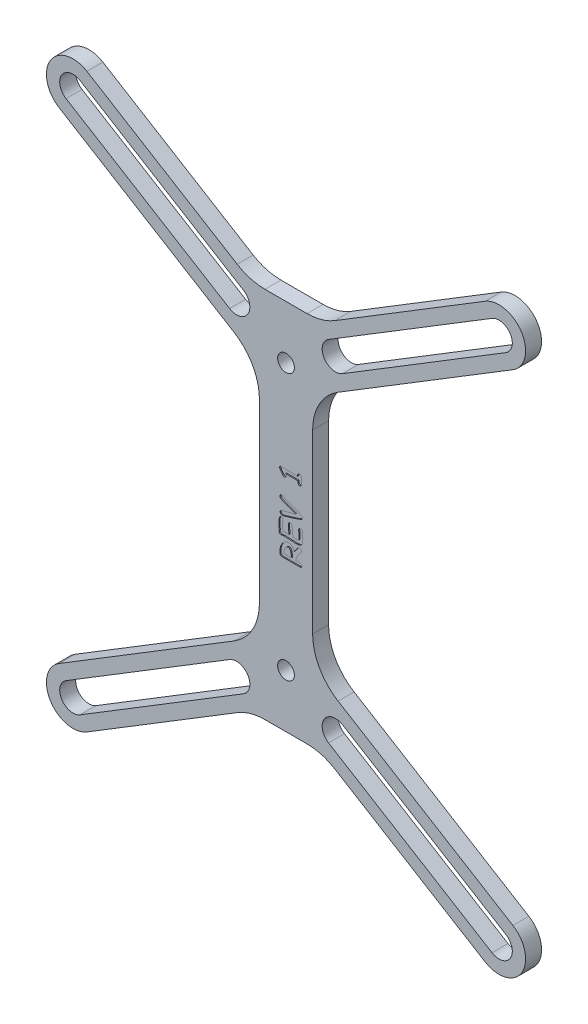
from build123d import *

# Parameters (mm, degrees)
SKETCH1_R           = 1.575
BOSS_EXTRUDE1_DEPTH = 3
CUT_EXTRUDE1_DEPTH  = 0.2


with BuildPart() as part:
    # Sketch1 → Boss-Extrude1 (new body)
    with BuildSketch(Plane.XY):
        with BuildLine():
            Line((-78.288917526, -9.797603918), (-50.063192097, -27.059285451))
            ThreePointArc((-50.063192097, -27.059285451), (-47.555969101, -28.153943521), (-44.845913527, -28.528165693))
            Line((-44.845913527, -28.528165693), (-36.940491232, -28.528165693))
            ThreePointArc((-36.940491232, -28.528165693), (-34.230435659, -28.153943521), (-31.723212662, -27.059285451))
            Line((-31.723212662, -27.059285451), (-3.497487233, -9.797603918))
            ThreePointArc((-3.497487233, -9.797603918), (3.37671193, -11.454524512), (1.719791336, -18.328723676))
            Line((1.719791336, -18.328723676), (-31.110480949, -38.406354852))
            ThreePointArc((-31.110480949, -38.406354852), (-34.615953829, -42.047320507), (-35.89320238, -46.93747461))
            Line((-35.89320238, -46.93747461), (-35.89320238, -80.118856775))
            ThreePointArc((-35.89320238, -80.118856775), (-34.615953829, -85.009010879), (-31.110480949, -88.649976534))
            Line((-31.110480949, -88.649976534), (1.719791336, -108.72760771))
            ThreePointArc((1.719791336, -108.72760771), (3.37671193, -115.601806874), (-3.497487233, -117.258727468))
            Line((-3.497487233, -117.258727468), (-31.723212662, -99.997045935))
            ThreePointArc((-31.723212662, -99.997045935), (-34.230435659, -98.902387865), (-36.940491232, -98.528165693))
            Line((-36.940491232, -98.528165693), (-44.845913527, -98.528165693))
            ThreePointArc((-44.845913527, -98.528165693), (-47.555969101, -98.902387865), (-50.063192097, -99.997045935))
            Line((-50.063192097, -99.997045935), (-78.288917526, -117.258727468))
            ThreePointArc((-78.288917526, -117.258727468), (-85.16311669, -115.601806874), (-83.506196095, -108.72760771))
            Line((-83.506196095, -108.72760771), (-50.67592381, -88.649976534))
            ThreePointArc((-50.67592381, -88.649976534), (-47.17045093, -85.009010879), (-45.89320238, -80.118856775))
            Line((-45.89320238, -80.118856775), (-45.89320238, -46.93747461))
            ThreePointArc((-45.89320238, -46.93747461), (-47.17045093, -42.047320507), (-50.67592381, -38.406354852))
            Line((-50.67592381, -38.406354852), (-83.506196095, -18.328723676))
            ThreePointArc((-83.506196095, -18.328723676), (-85.16311669, -11.454524512), (-78.288917526, -9.797603918))
        make_face()
        with Locations((-40.89320238, -88.528165693)):
            Circle(SKETCH1_R, mode=Mode.SUBTRACT)
        with Locations((-40.89320238, -38.528165693)):
            Circle(SKETCH1_R, mode=Mode.SUBTRACT)
        with BuildLine():
            Line((-82.201876453, -110.860387649), (-51.489845323, -92.078184799))
            ThreePointArc((-51.489845323, -92.078184799), (-48.052745742, -92.906645096), (-48.881206039, -96.343744678))
            Line((-48.881206039, -96.343744678), (-79.593237168, -115.125947528))
            ThreePointArc((-79.593237168, -115.125947528), (-83.03033675, -114.297487231), (-82.201876453, -110.860387649))
        make_face(mode=Mode.SUBTRACT)
        with BuildLine():
            Line((-30.296559436, -92.078184799), (0.415471694, -110.860387649))
            ThreePointArc((0.415471694, -110.860387649), (1.243931991, -114.297487231), (-2.193167591, -115.125947528))
            Line((-2.193167591, -115.125947528), (-32.90519872, -96.343744678))
            ThreePointArc((-32.90519872, -96.343744678), (-33.733659018, -92.906645096), (-30.296559436, -92.078184799))
        make_face(mode=Mode.SUBTRACT)
        with BuildLine():
            Line((-79.593237168, -11.930383857), (-48.881206039, -30.712586707))
            ThreePointArc((-48.881206039, -30.712586707), (-48.052745742, -34.149686289), (-51.489845323, -34.978146586))
            Line((-51.489845323, -34.978146586), (-82.201876453, -16.195943736))
            ThreePointArc((-82.201876453, -16.195943736), (-83.03033675, -12.758844154), (-79.593237168, -11.930383857))
        make_face(mode=Mode.SUBTRACT)
        with BuildLine():
            Line((0.415471694, -16.195943736), (-30.296559436, -34.978146586))
            ThreePointArc((-30.296559436, -34.978146586), (-33.733659018, -34.149686289), (-32.90519872, -30.712586707))
            Line((-32.90519872, -30.712586707), (-2.193167591, -11.930383857))
            ThreePointArc((-2.193167591, -11.930383857), (1.243931991, -12.758844154), (0.415471694, -16.195943736))
        make_face(mode=Mode.SUBTRACT)
    extrude(amount=BOSS_EXTRUDE1_DEPTH)

    # Sketch3 → Cut-Extrude1 (cut)
    with BuildSketch(Plane.XY.offset(3)):
        with BuildLine():
            add(Edge.make_bspline(
                [(-37.946643994, -67.703946943), (-37.94801712, -67.727536801), (-37.95073967, -67.774309314), (-37.972300047, -67.842742788), (-38.00796962, -67.907546345), (-38.040699509, -67.945888775), (-38.057581494, -67.965665693)],
                knots=[0, 0, 0, 0, 7.0663e-05, 0.000140107, 0.000213182, 0.000291025, 0.000291025, 0.000291025, 0.000291025], degree=3))
            add(Edge.make_bspline(
                [(-38.057581494, -67.965665693), (-38.118513774, -68.032704617), (-38.239038531, -68.165308384), (-38.404695199, -68.374150018), (-38.556288258, -68.587154817), (-38.693961893, -68.805219114), (-38.816172587, -69.028612594), (-38.925471999, -69.2564757), (-39.019782455, -69.489507045), (-39.071039403, -69.648662251), (-39.096643994, -69.728165693)],
                knots=[0, 0, 0, 0, 0.000271714, 0.000537454, 0.000799103, 0.00105574, 0.00131063, 0.001562578, 0.001813557, 0.002064069, 0.002064069, 0.002064069, 0.002064069], degree=3))
            add(Edge.make_bspline(
                [(-39.096643994, -69.728165693), (-39.03674816, -69.728165693), (-38.923987744, -69.728165693), (-38.765393994, -69.728165693), (-38.62815441, -69.728165693), (-38.512008577, -69.728165693), (-38.41721691, -69.728165693), (-38.343258577, -69.728165693), (-38.29065441, -69.728165693), (-38.26252941, -69.728165693), (-38.252112744, -69.728165693)],
                knots=[0, 0, 0, 0, 0.000179687, 0.000338281, 0.000475781, 0.000591406, 0.000686719, 0.000760156, 0.000813281, 0.000844531, 0.000844531, 0.000844531, 0.000844531], degree=3))
            add(Edge.make_bspline(
                [(-38.252112744, -69.728165693), (-38.228018483, -69.729273262), (-38.181130817, -69.731428604), (-38.113893955, -69.75106263), (-38.052563284, -69.782891975), (-37.998393202, -69.826613477), (-37.952764299, -69.879182157), (-37.920294463, -69.940102791), (-37.899713872, -70.007059626), (-37.897684969, -70.054054109), (-37.896643994, -70.078165693)],
                knots=[0, 0, 0, 0, 7.2146e-05, 0.000140397, 0.000208186, 0.00027822, 0.000348045, 0.000415509, 0.000483979, 0.000556125, 0.000556125, 0.000556125, 0.000556125], degree=3))
            add(Edge.make_bspline(
                [(-37.896643994, -70.078165693), (-37.897700605, -70.102269963), (-37.899759985, -70.149250191), (-37.920158621, -70.216429933), (-37.953627033, -70.277211505), (-37.999944638, -70.32947205), (-38.054228871, -70.373706451), (-38.116295574, -70.405238613), (-38.18426165, -70.424910627), (-38.231663247, -70.427060864), (-38.256018994, -70.428165693)],
                knots=[0, 0, 0, 0, 7.2146e-05, 0.000140616, 0.000208454, 0.000278789, 0.000348823, 0.000417306, 0.000486308, 0.000559233, 0.000559233, 0.000559233, 0.000559233], degree=3))
            add(Edge.make_bspline(
                [(-38.256018994, -70.428165693), (-38.29299816, -70.428165693), (-38.375289827, -70.428165693), (-38.511227327, -70.428165693), (-38.67190441, -70.428165693), (-38.848987744, -70.428165693), (-39.02581066, -70.428165693), (-39.186227327, -70.428165693), (-39.322164827, -70.428165693), (-39.40471691, -70.428165693), (-39.441956494, -70.428165693)],
                knots=[0, 0, 0, 0, 0.000110937, 0.000246875, 0.000407813, 0.000592969, 0.000778125, 0.000938281, 0.001074219, 0.001185937, 0.001185937, 0.001185937, 0.001185937], degree=3))
            Line((-39.441956494, -70.428165693), (-41.573987744, -70.428165693))
            add(Edge.make_bspline(
                [(-41.573987744, -70.428165693), (-41.601979025, -70.427059306), (-41.657620346, -70.42486002), (-41.73849047, -70.404276071), (-41.816039186, -70.372475538), (-41.862236056, -70.341021166), (-41.885706494, -70.325040693)],
                knots=[0, 0, 0, 0, 8.3827e-05, 0.000166632, 0.000248905, 0.000333871, 0.000333871, 0.000333871, 0.000333871], degree=3))
            add(Edge.make_bspline(
                [(-41.885706494, -70.325040693), (-41.900189952, -70.313770019), (-41.928533759, -70.291713562), (-41.963185459, -70.251611815), (-41.994098277, -70.210369522), (-42.016284314, -70.164185931), (-42.033902772, -70.115595291), (-42.044712726, -70.063280216), (-42.049515642, -70.007916377), (-42.047613317, -69.970094144), (-42.046643994, -69.950821943)],
                knots=[0, 0, 0, 0, 5.4916e-05, 0.000107469, 0.000158418, 0.000209079, 0.000260476, 0.000313185, 0.000368852, 0.000426686, 0.000426686, 0.000426686, 0.000426686], degree=3))
            add(Edge.make_bspline(
                [(-42.046643994, -69.950821943), (-42.04306086, -69.900556834), (-42.03633914, -69.806262856), (-42.026038224, -69.674782796), (-42.017465477, -69.562801844), (-42.010360978, -69.470620617), (-42.005041676, -69.397951), (-42.000741311, -69.344860312), (-41.999062241, -69.311184835), (-41.997196099, -69.295350376), (-41.996643994, -69.290665693)],
                knots=[0, 0, 0, 0, 0.000151177, 0.000283599, 0.000395648, 0.000488103, 0.000560965, 0.000614233, 0.000647908, 0.000662057, 0.000662057, 0.000662057, 0.000662057], degree=3))
            add(Edge.make_bspline(
                [(-41.996643994, -69.290665693), (-41.988273617, -69.230844456), (-41.972108507, -69.115315979), (-41.932255207, -68.950338653), (-41.883702436, -68.798492424), (-41.839811946, -68.705372819), (-41.818518994, -68.660196943)],
                knots=[0, 0, 0, 0, 0.000181103, 0.000349752, 0.000508607, 0.000658292, 0.000658292, 0.000658292, 0.000658292], degree=3))
            add(Edge.make_bspline(
                [(-41.818518994, -68.660196943), (-41.794961831, -68.614408759), (-41.748659411, -68.524410498), (-41.673994786, -68.39618382), (-41.596726829, -68.276980891), (-41.51936644, -68.16542509), (-41.4376406, -68.064104928), (-41.35488791, -67.970611015), (-41.269901128, -67.885903429), (-41.182031493, -67.810960226), (-41.093027121, -67.743861578), (-41.001103136, -67.68667641), (-40.907278255, -67.6381627), (-40.811252898, -67.597827282), (-40.712980642, -67.566485725), (-40.612487989, -67.544834027), (-40.510053033, -67.530917507), (-40.440959881, -67.529089918), (-40.406018994, -67.528165693)],
                knots=[0, 0, 0, 0, 0.00015446, 0.000303597, 0.000444889, 0.000580575, 0.000710638, 0.000835142, 0.00095502, 0.001070264, 0.001181358, 0.001289097, 0.001394621, 0.001497926, 0.001601205, 0.00170357, 0.001805997, 0.001910789, 0.001910789, 0.001910789, 0.001910789], degree=3))
            add(Edge.make_bspline(
                [(-40.406018994, -67.528165693), (-40.377335709, -67.528941421), (-40.320800891, -67.530470384), (-40.237423726, -67.541860235), (-40.156488148, -67.559578278), (-40.077988251, -67.585572136), (-40.002201476, -67.619243738), (-39.929157083, -67.660299744), (-39.858348954, -67.708085705), (-39.790568361, -67.763989432), (-39.724494721, -67.826431372), (-39.662291679, -67.897342845), (-39.601955567, -67.974597541), (-39.544855438, -68.059618408), (-39.490138913, -68.15198371), (-39.438169105, -68.252061425), (-39.387799267, -68.358955559), (-39.357971741, -68.43372714), (-39.342737744, -68.471915693)],
                knots=[0, 0, 0, 0, 8.6026e-05, 0.000169558, 0.000252008, 0.000334277, 0.000417171, 0.000500414, 0.000585354, 0.000673084, 0.000763709, 0.000857784, 0.000955768, 0.00105761, 0.001164798, 0.001277669, 0.001395803, 0.001519122, 0.001519122, 0.001519122, 0.001519122], degree=3))
            add(Edge.make_bspline(
                [(-39.342737744, -68.471915693), (-39.310298359, -68.415184995), (-39.24708115, -68.30462937), (-39.148196207, -68.146271602), (-39.048921734, -67.998721382), (-38.950303435, -67.860959497), (-38.850139699, -67.73478142), (-38.749002672, -67.620035159), (-38.648863696, -67.514397443), (-38.578568182, -67.451173738), (-38.544300244, -67.420353193)],
                knots=[0, 0, 0, 0, 0.000196038, 0.000382034, 0.00055993, 0.00072949, 0.000890179, 0.001042972, 0.001188287, 0.001326504, 0.001326504, 0.001326504, 0.001326504], degree=3))
            add(Edge.make_bspline(
                [(-38.544300244, -67.420353193), (-38.52682381, -67.406069168), (-38.492612419, -67.37810715), (-38.433863174, -67.34948095), (-38.372505499, -67.330996672), (-38.330370731, -67.329114099), (-38.309143994, -67.328165693)],
                knots=[0, 0, 0, 0, 6.75e-05, 0.000132137, 0.0001947, 0.000258217, 0.000258217, 0.000258217, 0.000258217], degree=3))
            add(Edge.make_bspline(
                [(-38.309143994, -67.328165693), (-38.285009966, -67.329428518), (-38.237591458, -67.331909716), (-38.169830124, -67.354305414), (-38.107059808, -67.389398259), (-38.052396515, -67.438547142), (-38.005316968, -67.495541419), (-37.970847449, -67.559935789), (-37.950843206, -67.63037859), (-37.94806328, -67.679081668), (-37.946643994, -67.703946943)],
                knots=[0, 0, 0, 0, 7.2218e-05, 0.000141894, 0.000211858, 0.000286602, 0.00036103, 0.000432675, 0.000504146, 0.000578697, 0.000578697, 0.000578697, 0.000578697], degree=3))
        make_face()
        with BuildLine():
            add(Edge.make_bspline(
                [(-41.275550244, -69.415665693), (-41.275804849, -69.418791139), (-41.276547596, -69.42790886), (-41.278302709, -69.445844221), (-41.279455784, -69.472193578), (-41.282026816, -69.507074291), (-41.285245279, -69.550280033), (-41.28812092, -69.602136058), (-41.292130522, -69.662286124), (-41.295073988, -69.70524956), (-41.296643994, -69.728165693)],
                knots=[0, 0, 0, 0, 9.407e-06, 2.7444e-05, 5.4052e-05, 8.8507e-05, 0.000132369, 0.000184026, 0.000244309, 0.000313218, 0.000313218, 0.000313218, 0.000313218], degree=3))
            Line((-41.296643994, -69.728165693), (-39.896643994, -69.728165693))
            add(Edge.make_bspline(
                [(-39.896643994, -69.728165693), (-39.896063647, -69.707333528), (-39.894975605, -69.668277055), (-39.894515115, -69.629208254), (-39.894300244, -69.610978193)],
                knots=[0, 0, 0, 0, 6.252e-05, 0.000117213, 0.000117213, 0.000117213, 0.000117213], degree=3))
            add(Edge.make_bspline(
                [(-39.894300244, -69.610978193), (-39.894643523, -69.558102426), (-39.89530682, -69.455934021), (-39.903370274, -69.308179304), (-39.915687067, -69.171083027), (-39.932438429, -69.044259041), (-39.95491402, -68.928163586), (-39.982105697, -68.822601569), (-40.014393423, -68.727547016), (-40.041464736, -68.669367701), (-40.054456494, -68.641446943)],
                knots=[0, 0, 0, 0, 0.000158611, 0.000306474, 0.000443763, 0.000571487, 0.000690078, 0.000798277, 0.000898341, 0.000990674, 0.000990674, 0.000990674, 0.000990674], degree=3))
            add(Edge.make_bspline(
                [(-40.054456494, -68.641446943), (-40.06666721, -68.61914395), (-40.091159557, -68.574408439), (-40.133384043, -68.509959676), (-40.182057134, -68.449034772), (-40.234559402, -68.393208766), (-40.285379775, -68.344648248), (-40.331179051, -68.307964677), (-40.371155024, -68.284056605), (-40.397234228, -68.279927615), (-40.408362744, -68.278165693)],
                knots=[0, 0, 0, 0, 7.6263e-05, 0.000152969, 0.000230812, 0.000309857, 0.000382811, 0.000441259, 0.000486342, 0.000519899, 0.000519899, 0.000519899, 0.000519899], degree=3))
            add(Edge.make_bspline(
                [(-40.408362744, -68.278165693), (-40.432934813, -68.279504973), (-40.482398518, -68.282200953), (-40.556302567, -68.300153316), (-40.629119914, -68.330119919), (-40.700849161, -68.372640378), (-40.772394938, -68.426010091), (-40.842120194, -68.492376657), (-40.912500765, -68.569179032), (-40.955493152, -68.626963701), (-40.977893994, -68.657071943)],
                knots=[0, 0, 0, 0, 7.3703e-05, 0.000148364, 0.000226852, 0.000309125, 0.000397875, 0.000494054, 0.000597478, 0.000709989, 0.000709989, 0.000709989, 0.000709989], degree=3))
            add(Edge.make_bspline(
                [(-40.977893994, -68.657071943), (-40.998549007, -68.687055273), (-41.039477072, -68.74646747), (-41.094121779, -68.838391065), (-41.141181343, -68.932043987), (-41.181644843, -69.026560274), (-41.216652114, -69.121733391), (-41.242785813, -69.218600458), (-41.263854527, -69.316313418), (-41.271647027, -69.382508816), (-41.275550244, -69.415665693)],
                knots=[0, 0, 0, 0, 0.000109207, 0.000216395, 0.000320513, 0.000423404, 0.000524726, 0.000624423, 0.00072417, 0.000824273, 0.000824273, 0.000824273, 0.000824273], degree=3))
        make_face(mode=Mode.SUBTRACT)
        with BuildLine():
            add(Edge.make_bspline(
                [(-41.446643994, -64.339884443), (-41.447277487, -64.357896108), (-41.448578566, -64.394888768), (-41.455044871, -64.431338352), (-41.458362744, -64.450040693)],
                knots=[0, 0, 0, 0, 5.3997e-05, 0.000110899, 0.000110899, 0.000110899, 0.000110899], degree=3))
            add(Edge.make_bspline(
                [(-41.458362744, -64.450040693), (-41.471768459, -64.520243843), (-41.498287495, -64.659118922), (-41.526438087, -64.867399853), (-41.543339495, -65.072672326), (-41.545550603, -65.208603896), (-41.546643994, -65.275821943)],
                knots=[0, 0, 0, 0, 0.000214383, 0.00042409, 0.000630213, 0.000831849, 0.000831849, 0.000831849, 0.000831849], degree=3))
            add(Edge.make_bspline(
                [(-41.546643994, -65.275821943), (-41.545348261, -65.343829472), (-41.542658029, -65.485028417), (-41.522665253, -65.703498576), (-41.491510464, -65.936554894), (-41.461951804, -66.095731476), (-41.446643994, -66.178165693)],
                knots=[0, 0, 0, 0, 0.000204002, 0.000423554, 0.00065768, 0.000909171, 0.000909171, 0.000909171, 0.000909171], degree=3))
            add(Edge.make_bspline(
                [(-41.446643994, -66.178165693), (-41.413831494, -66.178165693), (-41.34456066, -66.178165693), (-41.23518566, -66.178165693), (-41.114612744, -66.178165693), (-40.98284191, -66.178165693), (-40.839612744, -66.178165693), (-40.68518566, -66.178165693), (-40.51956066, -66.178165693), (-40.40549816, -66.178165693), (-40.346643994, -66.178165693)],
                knots=[0, 0, 0, 0, 9.8437e-05, 0.000207813, 0.000328125, 0.000460156, 0.000603125, 0.000757813, 0.000923437, 0.0011, 0.0011, 0.0011, 0.0011], degree=3))
            add(Edge.make_bspline(
                [(-40.346643994, -66.178165693), (-40.347358768, -66.162016044), (-40.349135186, -66.121879555), (-40.354506826, -66.050335643), (-40.359170949, -65.955723168), (-40.367860185, -65.838362667), (-40.375678834, -65.697655379), (-40.38710988, -65.53390121), (-40.39944828, -65.347172201), (-40.408346576, -65.215143822), (-40.413050244, -65.145353193)],
                knots=[0, 0, 0, 0, 4.8494e-05, 0.000120522, 0.000215211, 0.000332659, 0.000473546, 0.000637973, 0.00082511, 0.001034956, 0.001034956, 0.001034956, 0.001034956], degree=3))
            add(Edge.make_bspline(
                [(-40.413050244, -65.145353193), (-40.415630764, -65.105247588), (-40.420540428, -65.028943204), (-40.427909819, -64.920125372), (-40.433154649, -64.822699251), (-40.437755687, -64.73701893), (-40.44206484, -64.663090129), (-40.4441862, -64.600566342), (-40.445874027, -64.549526722), (-40.4464121, -64.519312252), (-40.446643994, -64.506290693)],
                knots=[0, 0, 0, 0, 0.000120566, 0.000229387, 0.000327196, 0.000413262, 0.000486803, 0.000549347, 0.000600933, 0.000640003, 0.000640003, 0.000640003, 0.000640003], degree=3))
            add(Edge.make_bspline(
                [(-40.446643994, -64.506290693), (-40.445419133, -64.481186429), (-40.443013155, -64.431874455), (-40.424834016, -64.361023994), (-40.394218322, -64.295954418), (-40.352553764, -64.237749816), (-40.300186943, -64.188965489), (-40.238862572, -64.152664397), (-40.168758672, -64.132043735), (-40.119694481, -64.129488309), (-40.094300244, -64.128165693)],
                knots=[0, 0, 0, 0, 7.526e-05, 0.000147832, 0.000217731, 0.000289932, 0.000361249, 0.000430925, 0.000501864, 0.000577971, 0.000577971, 0.000577971, 0.000577971], degree=3))
            add(Edge.make_bspline(
                [(-40.094300244, -64.128165693), (-40.069985476, -64.129154143), (-40.023665659, -64.131037149), (-39.958439623, -64.146838496), (-39.901181354, -64.172824743), (-39.852462524, -64.21063239), (-39.811978648, -64.259002659), (-39.781755908, -64.318530836), (-39.75875997, -64.387530724), (-39.750832997, -64.437628862), (-39.746643994, -64.464103193)],
                knots=[0, 0, 0, 0, 7.2862e-05, 0.000138802, 0.00019997, 0.000260131, 0.000322249, 0.000387599, 0.000459244, 0.000539535, 0.000539535, 0.000539535, 0.000539535], degree=3))
            add(Edge.make_bspline(
                [(-39.746643994, -64.464103193), (-39.745434569, -64.482860517), (-39.742879446, -64.52248868), (-39.736861174, -64.585163209), (-39.731513405, -64.654446344), (-39.726530362, -64.730305751), (-39.718825712, -64.812502076), (-39.712246149, -64.901361876), (-39.704306373, -64.996664583), (-39.698736431, -65.062281076), (-39.695862744, -65.096134443)],
                knots=[0, 0, 0, 0, 5.6385e-05, 0.000119124, 0.00018887, 0.000264849, 0.000347181, 0.00043652, 0.000532152, 0.000634078, 0.000634078, 0.000634078, 0.000634078], degree=3))
            add(Edge.make_bspline(
                [(-39.695862744, -65.096134443), (-39.692452325, -65.129465262), (-39.685233205, -65.200019399), (-39.67433901, -65.311743236), (-39.662631191, -65.4354423), (-39.649998011, -65.570825189), (-39.637704493, -65.718263008), (-39.624408325, -65.877636321), (-39.61020746, -66.048959508), (-39.60125658, -66.167222278), (-39.596643994, -66.228165693)],
                knots=[0, 0, 0, 0, 0.000100514, 0.000212767, 0.00033676, 0.000473271, 0.000620677, 0.000780604, 0.000953054, 0.001136406, 0.001136406, 0.001136406, 0.001136406], degree=3))
            add(Edge.make_bspline(
                [(-39.596643994, -66.228165693), (-39.545602327, -66.228165693), (-39.448727327, -66.228165693), (-39.311227327, -66.228165693), (-39.189352327, -66.228165693), (-39.11331066, -66.228165693), (-39.077893994, -66.228165693)],
                knots=[0, 0, 0, 0, 0.000153125, 0.000290625, 0.0004125, 0.00051875, 0.00051875, 0.00051875, 0.00051875], degree=3))
            add(Edge.make_bspline(
                [(-39.077893994, -66.228165693), (-39.038829788, -66.228036152), (-38.965120613, -66.227791725), (-38.861200099, -66.225475728), (-38.770788259, -66.221812841), (-38.693694104, -66.216369514), (-38.629939228, -66.209955983), (-38.579486038, -66.201121551), (-38.541383074, -66.192871111), (-38.522299535, -66.182388184), (-38.514612744, -66.178165693)],
                knots=[0, 0, 0, 0, 0.00011719, 0.000221123, 0.000311832, 0.000388589, 0.000453037, 0.00050377, 0.000542621, 0.000568825, 0.000568825, 0.000568825, 0.000568825], degree=3))
            add(Edge.make_bspline(
                [(-38.514612744, -66.178165693), (-38.511811666, -66.174363836), (-38.504735637, -66.164759655), (-38.498624267, -66.14331258), (-38.493682834, -66.114007242), (-38.489024571, -66.075897483), (-38.485121891, -66.029277603), (-38.483182118, -65.973749196), (-38.481547919, -65.909685841), (-38.481202525, -65.864104795), (-38.481018994, -65.839884443)],
                knots=[0, 0, 0, 0, 1.4084e-05, 3.5579e-05, 6.5766e-05, 0.000103558, 0.000150596, 0.000206114, 0.000270195, 0.000342856, 0.000342856, 0.000342856, 0.000342856], degree=3))
            add(Edge.make_bspline(
                [(-38.481018994, -65.839884443), (-38.481322747, -65.80863501), (-38.482001125, -65.738845069), (-38.482050482, -65.62371905), (-38.486214995, -65.487550084), (-38.488711645, -65.337278191), (-38.491922888, -65.187024042), (-38.494248705, -65.050564916), (-38.495910082, -64.935460656), (-38.496417015, -64.865666038), (-38.496643994, -64.834415693)],
                knots=[0, 0, 0, 0, 9.3753e-05, 0.000209381, 0.000345354, 0.000502417, 0.00066026, 0.000796218, 0.000911853, 0.001005607, 0.001005607, 0.001005607, 0.001005607], degree=3))
            add(Edge.make_bspline(
                [(-38.496643994, -64.834415693), (-38.496789943, -64.824514692), (-38.497116999, -64.802327702), (-38.500479829, -64.766085657), (-38.506314988, -64.723447244), (-38.512937335, -64.676589891), (-38.520239503, -64.629583396), (-38.52443865, -64.5870453), (-38.528275926, -64.551409652), (-38.528551254, -64.529996361), (-38.528675244, -64.520353193)],
                knots=[0, 0, 0, 0, 2.9698e-05, 6.6549e-05, 0.00010909, 0.000158808, 0.000208527, 0.00025175, 0.000287045, 0.000315962, 0.000315962, 0.000315962, 0.000315962], degree=3))
            add(Edge.make_bspline(
                [(-38.528675244, -64.520353193), (-38.527785396, -64.495227612), (-38.526048005, -64.446170954), (-38.507813878, -64.376191778), (-38.481003514, -64.310865485), (-38.453464995, -64.273515664), (-38.439612744, -64.254728193)],
                knots=[0, 0, 0, 0, 7.5199e-05, 0.000146823, 0.000215759, 0.000285532, 0.000285532, 0.000285532, 0.000285532], degree=3))
            add(Edge.make_bspline(
                [(-38.439612744, -64.254728193), (-38.422264593, -64.235242603), (-38.387966383, -64.19671856), (-38.320349562, -64.156046756), (-38.242765378, -64.132203952), (-38.187707091, -64.129545067), (-38.159143994, -64.128165693)],
                knots=[0, 0, 0, 0, 7.7894e-05, 0.000154001, 0.000233324, 0.000318838, 0.000318838, 0.000318838, 0.000318838], degree=3))
            add(Edge.make_bspline(
                [(-38.159143994, -64.128165693), (-38.135095487, -64.12889386), (-38.089091216, -64.130286827), (-38.024069442, -64.145529817), (-37.966332465, -64.169857998), (-37.916298927, -64.204520623), (-37.874859863, -64.250112454), (-37.840194176, -64.30427868), (-37.814400764, -64.369105644), (-37.803787742, -64.416002995), (-37.798206494, -64.440665693)],
                knots=[0, 0, 0, 0, 7.2028e-05, 0.000137787, 0.00019903, 0.000259064, 0.000318767, 0.000382701, 0.000451032, 0.000526826, 0.000526826, 0.000526826, 0.000526826], degree=3))
            add(Edge.make_bspline(
                [(-37.798206494, -64.440665693), (-37.794128823, -64.465900775), (-37.785032055, -64.522197064), (-37.77418292, -64.616251288), (-37.766494793, -64.728378707), (-37.758124725, -64.858284989), (-37.753267842, -65.006006447), (-37.749329574, -65.171636573), (-37.747048934, -65.355242964), (-37.746783104, -65.483633915), (-37.746643994, -65.550821943)],
                knots=[0, 0, 0, 0, 7.6682e-05, 0.000171068, 0.000283896, 0.000413818, 0.000561576, 0.000727247, 0.000910855, 0.001112419, 0.001112419, 0.001112419, 0.001112419], degree=3))
            add(Edge.make_bspline(
                [(-37.746643994, -65.550821943), (-37.747367701, -65.620370764), (-37.748748334, -65.753050673), (-37.759755063, -65.942546525), (-37.776850311, -66.113251492), (-37.80255544, -66.265104423), (-37.834213838, -66.398602231), (-37.874992936, -66.51263274), (-37.921165225, -66.609377724), (-37.961913509, -66.662058989), (-37.981018994, -66.686759443)],
                knots=[0, 0, 0, 0, 0.00020863, 0.000398009, 0.000569267, 0.000723006, 0.000859812, 0.000980158, 0.001086022, 0.001179475, 0.001179475, 0.001179475, 0.001179475], degree=3))
            add(Edge.make_bspline(
                [(-37.981018994, -66.686759443), (-38.004989368, -66.710355123), (-38.055233923, -66.759814278), (-38.150653105, -66.81840324), (-38.263378456, -66.867883721), (-38.394569488, -66.909370457), (-38.544598935, -66.940368871), (-38.713266925, -66.962632418), (-38.900348366, -66.975564246), (-39.031258502, -66.977271972), (-39.099768994, -66.978165693)],
                knots=[0, 0, 0, 0, 0.000100639, 0.00021095, 0.000333347, 0.000469484, 0.000622866, 0.000792356, 0.000979547, 0.001185069, 0.001185069, 0.001185069, 0.001185069], degree=3))
            add(Edge.make_bspline(
                [(-39.099768994, -66.978165693), (-39.131280588, -66.977996147), (-39.198217579, -66.977635997), (-39.304213641, -66.975117221), (-39.421405587, -66.971193577), (-39.549792407, -66.96564269), (-39.689378643, -66.958602901), (-39.840160305, -66.949964994), (-40.002140449, -66.939785412), (-40.171644056, -66.92816675), (-40.341147295, -66.916541888), (-40.502868962, -66.906395549), (-40.653127975, -66.89772983), (-40.792192464, -66.890668071), (-40.920319972, -66.885138359), (-41.037251741, -66.881228123), (-41.14272654, -66.878694667), (-41.209142795, -66.878334952), (-41.240393994, -66.878165693)],
                knots=[0, 0, 0, 0, 9.4534e-05, 0.00020081, 0.000318063, 0.000446305, 0.000586325, 0.000737351, 0.000899388, 0.001073221, 0.001247054, 0.001409092, 0.001559338, 0.001698578, 0.001826819, 0.001944072, 0.002049567, 0.00214332, 0.00214332, 0.00214332, 0.00214332], degree=3))
            add(Edge.make_bspline(
                [(-41.240393994, -66.878165693), (-41.257849467, -66.878525626), (-41.296456222, -66.879321701), (-41.360014828, -66.884534589), (-41.434778173, -66.892290417), (-41.516704107, -66.903104571), (-41.598352099, -66.914039966), (-41.67259223, -66.921835765), (-41.735894577, -66.927006379), (-41.774501117, -66.92780473), (-41.791956494, -66.928165693)],
                knots=[0, 0, 0, 0, 5.2367e-05, 0.000115822, 0.000191227, 0.000277858, 0.000363714, 0.000438343, 0.000501797, 0.000554164, 0.000554164, 0.000554164, 0.000554164], degree=3))
            add(Edge.make_bspline(
                [(-41.791956494, -66.928165693), (-41.823551279, -66.927295069), (-41.883366798, -66.925646797), (-41.96701943, -66.908765258), (-42.038282434, -66.880087842), (-42.096511964, -66.839074154), (-42.142584377, -66.786899688), (-42.174999964, -66.722443997), (-42.193532622, -66.646633819), (-42.195569822, -66.592596116), (-42.196643994, -66.564103193)],
                knots=[0, 0, 0, 0, 9.4689e-05, 0.000179267, 0.000254567, 0.000323499, 0.00039104, 0.00046127, 0.00053782, 0.000623206, 0.000623206, 0.000623206, 0.000623206], degree=3))
            add(Edge.make_bspline(
                [(-42.196643994, -66.564103193), (-42.195973599, -66.545278643), (-42.194645281, -66.507979732), (-42.181504769, -66.453397536), (-42.160405873, -66.401196001), (-42.140374835, -66.369304832), (-42.130237744, -66.353165693)],
                knots=[0, 0, 0, 0, 5.6385e-05, 0.000111722, 0.000167432, 0.000224512, 0.000224512, 0.000224512, 0.000224512], degree=3))
            add(Edge.make_bspline(
                [(-42.130237744, -66.353165693), (-42.14146284, -66.303488234), (-42.163551482, -66.205733384), (-42.191207567, -66.060463944), (-42.211534832, -65.918881553), (-42.229541057, -65.73760341), (-42.24301867, -65.520299091), (-42.245460978, -65.34875766), (-42.246643994, -65.265665693)],
                knots=[0, 0, 0, 0, 0.000152784, 0.000300647, 0.000443504, 0.000581722, 0.000847073, 0.001096352, 0.001096352, 0.001096352, 0.001096352], degree=3))
            add(Edge.make_bspline(
                [(-42.246643994, -65.265665693), (-42.246218855, -65.212272154), (-42.245390999, -65.108301166), (-42.238268384, -64.95664684), (-42.226710529, -64.813308622), (-42.210402768, -64.67802657), (-42.189565521, -64.550754482), (-42.163826046, -64.431840824), (-42.133803816, -64.32105438), (-42.108802934, -64.25120081), (-42.096643994, -64.217228193)],
                knots=[0, 0, 0, 0, 0.000160173, 0.000311899, 0.000455347, 0.000591495, 0.000720574, 0.000842091, 0.000956383, 0.001064597, 0.001064597, 0.001064597, 0.001064597], degree=3))
            add(Edge.make_bspline(
                [(-42.096643994, -64.217228193), (-42.089331819, -64.198257077), (-42.07529865, -64.161848636), (-42.047002347, -64.112716832), (-42.013446878, -64.071731135), (-41.977197413, -64.036647239), (-41.935073711, -64.01021683), (-41.888813652, -63.991499563), (-41.838038948, -63.980449916), (-41.802948304, -63.978940798), (-41.784925244, -63.978165693)],
                knots=[0, 0, 0, 0, 6.0937e-05, 0.000116948, 0.000169169, 0.000219468, 0.000267583, 0.000317344, 0.000368526, 0.000422574, 0.000422574, 0.000422574, 0.000422574], degree=3))
            add(Edge.make_bspline(
                [(-41.784925244, -63.978165693), (-41.76423682, -63.979473747), (-41.723184076, -63.982069364), (-41.663433212, -63.999764739), (-41.607579878, -64.029964347), (-41.575564681, -64.058209779), (-41.559143994, -64.072696943)],
                knots=[0, 0, 0, 0, 6.2034e-05, 0.000123097, 0.000185323, 0.000250846, 0.000250846, 0.000250846, 0.000250846], degree=3))
            add(Edge.make_bspline(
                [(-41.559143994, -64.072696943), (-41.541876895, -64.090777448), (-41.508043609, -64.126204531), (-41.472014322, -64.191186026), (-41.450439994, -64.263253649), (-41.447928657, -64.313950633), (-41.446643994, -64.339884443)],
                knots=[0, 0, 0, 0, 7.4743e-05, 0.000146452, 0.000220609, 0.000298272, 0.000298272, 0.000298272, 0.000298272], degree=3))
        make_face()
        with BuildLine():
            add(Edge.make_bspline(
                [(-39.100550244, -62.203165693), (-39.182047295, -62.171100392), (-39.340812435, -62.10863369), (-39.572839243, -62.017995379), (-39.792167024, -61.932984319), (-39.998634255, -61.85318568), (-40.191967941, -61.778811113), (-40.373017531, -61.711169017), (-40.540594914, -61.647357572), (-40.648682454, -61.607993004), (-40.700550244, -61.589103193)],
                knots=[0, 0, 0, 0, 0.000262735, 0.000511836, 0.000747305, 0.000968414, 0.001175893, 0.001368736, 0.00154823, 0.001713829, 0.001713829, 0.001713829, 0.001713829], degree=3))
            add(Edge.make_bspline(
                [(-40.700550244, -61.589103193), (-40.805709522, -61.550686035), (-41.016092069, -61.473828343), (-41.227063629, -61.398602536), (-41.332581494, -61.360978193)],
                knots=[0, 0, 0, 0, 0.000335869, 0.000671943, 0.000671943, 0.000671943, 0.000671943], degree=3))
            add(Edge.make_bspline(
                [(-41.332581494, -61.360978193), (-41.392103865, -61.335533711), (-41.505529975, -61.287046588), (-41.661068905, -61.204513223), (-41.796715643, -61.121331202), (-41.874567568, -61.058135406), (-41.911487744, -61.028165693)],
                knots=[0, 0, 0, 0, 0.000194106, 0.000369889, 0.000527896, 0.000670418, 0.000670418, 0.000670418, 0.000670418], degree=3))
            add(Edge.make_bspline(
                [(-41.911487744, -61.028165693), (-41.932258522, -61.008694732), (-41.972397172, -60.971067926), (-42.015198575, -60.902022889), (-42.041841743, -60.827203693), (-42.045026013, -60.775002493), (-42.046643994, -60.748478193)],
                knots=[0, 0, 0, 0, 8.5081e-05, 0.000164415, 0.000241252, 0.000320625, 0.000320625, 0.000320625, 0.000320625], degree=3))
            add(Edge.make_bspline(
                [(-42.046643994, -60.748478193), (-42.045583769, -60.724371322), (-42.043506339, -60.677135706), (-42.022722975, -60.608878474), (-41.989398689, -60.54565774), (-41.944095285, -60.488632319), (-41.890746585, -60.438988156), (-41.828100451, -60.404362184), (-41.760395717, -60.381894943), (-41.712969463, -60.379423536), (-41.688831494, -60.378165693)],
                knots=[0, 0, 0, 0, 7.2146e-05, 0.000141365, 0.000211955, 0.000285409, 0.000358984, 0.000428948, 0.000498624, 0.000570842, 0.000570842, 0.000570842, 0.000570842], degree=3))
            add(Edge.make_bspline(
                [(-41.688831494, -60.378165693), (-41.671303601, -60.379149583), (-41.635764474, -60.381144495), (-41.582716456, -60.395163116), (-41.530052769, -60.417877729), (-41.497147182, -60.43912315), (-41.480237744, -60.450040693)],
                knots=[0, 0, 0, 0, 5.2553e-05, 0.000106556, 0.000163592, 0.000223885, 0.000223885, 0.000223885, 0.000223885], degree=3))
            add(Edge.make_bspline(
                [(-41.480237744, -60.450040693), (-41.444570765, -60.473907974), (-41.370989094, -60.523146639), (-41.252192896, -60.590614957), (-41.122810276, -60.654673885), (-41.032243406, -60.6939312), (-40.985706494, -60.714103193)],
                knots=[0, 0, 0, 0, 0.000128714, 0.00026554, 0.000409487, 0.000561631, 0.000561631, 0.000561631, 0.000561631], degree=3))
            add(Edge.make_bspline(
                [(-40.985706494, -60.714103193), (-40.982053497, -60.715386214), (-40.969684976, -60.719730338), (-40.943609082, -60.730485199), (-40.901861226, -60.74641568), (-40.84446612, -60.768709392), (-40.771203122, -60.795394802), (-40.682773688, -60.829717501), (-40.57824818, -60.868087349), (-40.503641044, -60.8965644), (-40.463831494, -60.911759443)],
                knots=[0, 0, 0, 0, 1.1614e-05, 3.9324e-05, 8.4589e-05, 0.000145672, 0.000224035, 0.000318492, 0.000430229, 0.000558061, 0.000558061, 0.000558061, 0.000558061], degree=3))
            add(Edge.make_bspline(
                [(-40.463831494, -60.911759443), (-40.409917724, -60.932834004), (-40.295785359, -60.977447646), (-40.115289326, -61.048473324), (-39.916231785, -61.127931155), (-39.697287075, -61.212447766), (-39.459845775, -61.305567473), (-39.203546195, -61.406625596), (-38.927933841, -61.51420548), (-38.737792636, -61.588329215), (-38.639612744, -61.626603193)],
                knots=[0, 0, 0, 0, 0.000173659, 0.000367626, 0.000581903, 0.000816643, 0.001071691, 0.001347047, 0.001643153, 0.001959282, 0.001959282, 0.001959282, 0.001959282], degree=3))
            add(Edge.make_bspline(
                [(-38.639612744, -61.626603193), (-38.586310134, -61.647796366), (-38.478846437, -61.690524043), (-38.319566468, -61.762929605), (-38.159915916, -61.841548523), (-38.055028391, -61.899120627), (-38.002112744, -61.928165693)],
                knots=[0, 0, 0, 0, 0.000172061, 0.000346894, 0.000524732, 0.000705801, 0.000705801, 0.000705801, 0.000705801], degree=3))
            add(Edge.make_bspline(
                [(-38.002112744, -61.928165693), (-37.985701521, -61.936853292), (-37.954122459, -61.953570282), (-37.912627203, -61.984672332), (-37.876425619, -62.017517658), (-37.847645036, -62.054514414), (-37.824675693, -62.09389592), (-37.807637604, -62.136118845), (-37.798451076, -62.18167329), (-37.797252669, -62.213023863), (-37.796643994, -62.228946943)],
                knots=[0, 0, 0, 0, 5.5623e-05, 0.000107031, 0.000155121, 0.000201852, 0.00024701, 0.000291548, 0.00033782, 0.000385578, 0.000385578, 0.000385578, 0.000385578], degree=3))
            add(Edge.make_bspline(
                [(-37.796643994, -62.228946943), (-37.797245364, -62.249082255), (-37.798413956, -62.288209492), (-37.81174995, -62.3441289), (-37.830908808, -62.395973155), (-37.859636259, -62.442850527), (-37.896992876, -62.484146083), (-37.94120222, -62.521740624), (-37.994503637, -62.552764235), (-38.033428802, -62.569474208), (-38.053675244, -62.578165693)],
                knots=[0, 0, 0, 0, 6.0283e-05, 0.000117143, 0.00017155, 0.000225547, 0.000280889, 0.000338006, 0.000398969, 0.000465048, 0.000465048, 0.000465048, 0.000465048], degree=3))
            add(Edge.make_bspline(
                [(-38.053675244, -62.578165693), (-38.120451505, -62.606145666), (-38.260520906, -62.664836256), (-38.483108607, -62.74902345), (-38.726513924, -62.836869569), (-38.991065144, -62.926174888), (-39.276503136, -63.018371498), (-39.582896198, -63.113140348), (-39.910877098, -63.208554179), (-40.136709536, -63.272573366), (-40.252893994, -63.305509443)],
                knots=[0, 0, 0, 0, 0.000217189, 0.000455574, 0.000713818, 0.000993486, 0.001293173, 0.001613681, 0.001955588, 0.002317876, 0.002317876, 0.002317876, 0.002317876], degree=3))
            add(Edge.make_bspline(
                [(-40.252893994, -63.305509443), (-40.370918544, -63.342050803), (-40.60719159, -63.41520286), (-40.842793756, -63.49048763), (-40.960706494, -63.528165693)],
                knots=[0, 0, 0, 0, 0.000370654, 0.00074201, 0.00074201, 0.00074201, 0.00074201], degree=3))
            add(Edge.make_bspline(
                [(-40.960706494, -63.528165693), (-41.000258497, -63.539990275), (-41.075831069, -63.562583671), (-41.1848776, -63.593372199), (-41.284424717, -63.618979108), (-41.374726472, -63.640472964), (-41.455514925, -63.656848625), (-41.527130425, -63.668848344), (-41.589189798, -63.676430713), (-41.6276173, -63.677623573), (-41.645081494, -63.678165693)],
                knots=[0, 0, 0, 0, 0.000123845, 0.000236632, 0.000339902, 0.000432189, 0.000515078, 0.000587132, 0.000650026, 0.000702422, 0.000702422, 0.000702422, 0.000702422], degree=3))
            add(Edge.make_bspline(
                [(-41.645081494, -63.678165693), (-41.6699965, -63.676646552), (-41.718501142, -63.673689081), (-41.787916568, -63.650862517), (-41.850580309, -63.612540459), (-41.884615598, -63.576937506), (-41.902112744, -63.558634443)],
                knots=[0, 0, 0, 0, 7.4629e-05, 0.000145288, 0.000216839, 0.00029254, 0.00029254, 0.00029254, 0.00029254], degree=3))
            add(Edge.make_bspline(
                [(-41.902112744, -63.558634443), (-41.916659119, -63.539312851), (-41.945394191, -63.501144763), (-41.975444734, -63.435599252), (-41.992768028, -63.365259858), (-41.995339742, -63.316803142), (-41.996643994, -63.292228193)],
                knots=[0, 0, 0, 0, 7.2387e-05, 0.000142994, 0.000214618, 0.000288321, 0.000288321, 0.000288321, 0.000288321], degree=3))
            add(Edge.make_bspline(
                [(-41.996643994, -63.292228193), (-41.996022608, -63.271320504), (-41.994814303, -63.23066484), (-41.981713516, -63.172257366), (-41.961582354, -63.118176778), (-41.932229529, -63.069445167), (-41.895042558, -63.025492805), (-41.848484367, -62.988278792), (-41.795295573, -62.953784692), (-41.755038153, -62.936919146), (-41.734143994, -62.928165693)],
                knots=[0, 0, 0, 0, 6.2622e-05, 0.00012177, 0.000178646, 0.000235053, 0.000291574, 0.000350391, 0.000413247, 0.000481072, 0.000481072, 0.000481072, 0.000481072], degree=3))
            add(Edge.make_bspline(
                [(-41.734143994, -62.928165693), (-41.658096098, -62.911266494), (-41.506496511, -62.87757836), (-41.354971179, -62.843557798), (-41.279456494, -62.826603193)],
                knots=[0, 0, 0, 0, 0.000233709, 0.000465892, 0.000465892, 0.000465892, 0.000465892], degree=3))
            add(Edge.make_bspline(
                [(-41.279456494, -62.826603193), (-41.254197389, -62.819307001), (-41.200826874, -62.803890718), (-41.116464824, -62.779626196), (-41.023108693, -62.753246534), (-40.921632479, -62.723120807), (-40.810363655, -62.693042925), (-40.690903147, -62.659457817), (-40.56231042, -62.623329837), (-40.473733605, -62.598716107), (-40.427893994, -62.585978193)],
                knots=[0, 0, 0, 0, 7.8875e-05, 0.000166657, 0.000263346, 0.000369909, 0.000484201, 0.000609116, 0.000742185, 0.000884915, 0.000884915, 0.000884915, 0.000884915], degree=3))
            add(Edge.make_bspline(
                [(-40.427893994, -62.585978193), (-40.306224474, -62.553369886), (-40.069876625, -62.490026963), (-39.726833639, -62.394482513), (-39.406201779, -62.298871591), (-39.200221833, -62.234374955), (-39.100550244, -62.203165693)],
                knots=[0, 0, 0, 0, 0.00037789, 0.000734066, 0.001068259, 0.001381588, 0.001381588, 0.001381588, 0.001381588], degree=3))
        make_face()
        with BuildLine():
            Line((-37.996643994, -55.688321943), (-37.996643994, -56.731290693))
            add(Edge.make_bspline(
                [(-37.996643994, -56.731290693), (-37.997289636, -56.770162427), (-37.99849983, -56.843023744), (-38.013809544, -56.94457274), (-38.035693257, -57.031569595), (-38.069601264, -57.103286796), (-38.113515378, -57.159685893), (-38.168388947, -57.199824503), (-38.232995333, -57.224269189), (-38.279496772, -57.226832761), (-38.303675244, -57.228165693)],
                knots=[0, 0, 0, 0, 0.000116501, 0.000218369, 0.000307445, 0.000384667, 0.000454701, 0.000519549, 0.000586299, 0.000658598, 0.000658598, 0.000658598, 0.000658598], degree=3))
            add(Edge.make_bspline(
                [(-38.303675244, -57.228165693), (-38.330983381, -57.226675363), (-38.382987888, -57.22383724), (-38.455746254, -57.197719785), (-38.516967579, -57.154128176), (-38.566388871, -57.092854655), (-38.604654061, -57.015574888), (-38.630086066, -56.921415026), (-38.646459085, -56.811549262), (-38.648109269, -56.732661559), (-38.648987744, -56.690665693)],
                knots=[0, 0, 0, 0, 8.1703e-05, 0.000155592, 0.000228429, 0.000304451, 0.000389353, 0.000485291, 0.000595889, 0.00072179, 0.00072179, 0.00072179, 0.00072179], degree=3))
            add(Edge.make_bspline(
                [(-38.648987744, -56.690665693), (-38.6487797, -56.672695865), (-38.648345466, -56.635188724), (-38.647226736, -56.597695669), (-38.646643994, -56.578165693)],
                knots=[0, 0, 0, 0, 5.3912e-05, 0.000112526, 0.000112526, 0.000112526, 0.000112526], degree=3))
            Line((-38.646643994, -56.578165693), (-41.004456494, -56.578165693))
            add(Edge.make_bspline(
                [(-41.004456494, -56.578165693), (-40.992173975, -56.596105452), (-40.968955994, -56.630017471), (-40.936675395, -56.678560672), (-40.909241059, -56.722291921), (-40.886690569, -56.761012043), (-40.868768782, -56.794660677), (-40.85749829, -56.823980285), (-40.848331228, -56.847942211), (-40.847156264, -56.86300482), (-40.846643994, -56.869571943)],
                knots=[0, 0, 0, 0, 6.5224e-05, 0.000123294, 0.000174887, 0.000220044, 0.000257779, 0.00028897, 0.000314418, 0.000334089, 0.000334089, 0.000334089, 0.000334089], degree=3))
            add(Edge.make_bspline(
                [(-40.846643994, -56.869571943), (-40.847765067, -56.892885363), (-40.849985668, -56.939064109), (-40.87024544, -57.005726087), (-40.904180849, -57.067316991), (-40.949706508, -57.12210802), (-41.002809121, -57.169114498), (-41.062177051, -57.203543491), (-41.126345979, -57.223862297), (-41.170462968, -57.226721882), (-41.192737744, -57.228165693)],
                knots=[0, 0, 0, 0, 6.9812e-05, 0.000138281, 0.000206805, 0.000279528, 0.000350964, 0.000418505, 0.000483986, 0.000550763, 0.000550763, 0.000550763, 0.000550763], degree=3))
            add(Edge.make_bspline(
                [(-41.192737744, -57.228165693), (-41.217315687, -57.225930653), (-41.26856127, -57.221270543), (-41.343141733, -57.184334091), (-41.418137373, -57.128772272), (-41.463098594, -57.079599924), (-41.487268994, -57.053165693)],
                knots=[0, 0, 0, 0, 7.3475e-05, 0.000153197, 0.000245388, 0.000352564, 0.000352564, 0.000352564, 0.000352564], degree=3))
            Line((-41.487268994, -57.053165693), (-41.700550244, -56.758634443))
            Line((-41.700550244, -56.758634443), (-41.956018994, -56.440665693))
            add(Edge.make_bspline(
                [(-41.956018994, -56.440665693), (-41.977587693, -56.408942937), (-42.018849018, -56.34825671), (-42.062626598, -56.251644217), (-42.091585944, -56.1569257), (-42.09498693, -56.093462087), (-42.096643994, -56.062540693)],
                knots=[0, 0, 0, 0, 0.000114865, 0.000219739, 0.000317179, 0.000409766, 0.000409766, 0.000409766, 0.000409766], degree=3))
            add(Edge.make_bspline(
                [(-42.096643994, -56.062540693), (-42.095796991, -56.044217144), (-42.094186557, -56.009378), (-42.080673678, -55.96061183), (-42.058749359, -55.918768069), (-42.026879193, -55.884675671), (-41.986025416, -55.858645356), (-41.936335574, -55.841085869), (-41.878367052, -55.830148965), (-41.836803858, -55.828856015), (-41.814612744, -55.828165693)],
                knots=[0, 0, 0, 0, 5.4888e-05, 0.00010436, 0.0001505, 0.000195278, 0.000242735, 0.000294398, 0.000352469, 0.00041899, 0.00041899, 0.00041899, 0.00041899], degree=3))
            add(Edge.make_bspline(
                [(-41.814612744, -55.828165693), (-41.787267703, -55.828032817), (-41.730229192, -55.827755652), (-41.640659359, -55.830044675), (-41.543237153, -55.830860124), (-41.437800154, -55.834793539), (-41.324478397, -55.837142488), (-41.203170534, -55.842669046), (-41.073949659, -55.846494487), (-40.935743793, -55.8538181), (-40.785968928, -55.858690279), (-40.622458921, -55.864799015), (-40.443516624, -55.867924274), (-40.249787266, -55.872541445), (-40.040652041, -55.874088208), (-39.816703803, -55.877146451), (-39.577632552, -55.877266889), (-39.413310295, -55.877860137), (-39.328675244, -55.878165693)],
                knots=[0, 0, 0, 0, 8.2031e-05, 0.000171107, 0.000268776, 0.000374291, 0.000487616, 0.0006088, 0.000738572, 0.000875434, 0.001023972, 0.001188126, 0.001366293, 0.001560864, 0.001769471, 0.001993702, 0.002232766, 0.002486673, 0.002486673, 0.002486673, 0.002486673], degree=3))
            Line((-39.328675244, -55.878165693), (-38.696643994, -55.878165693))
            Line((-38.696643994, -55.878165693), (-38.696643994, -55.699259443))
            add(Edge.make_bspline(
                [(-38.696643994, -55.699259443), (-38.695559799, -55.673862906), (-38.693459532, -55.624665523), (-38.67371534, -55.554162483), (-38.642444314, -55.489890394), (-38.598208347, -55.433919818), (-38.545589768, -55.386572515), (-38.484698314, -55.352649168), (-38.417458335, -55.332156229), (-38.370749085, -55.329524065), (-38.346643994, -55.328165693)],
                knots=[0, 0, 0, 0, 7.6039e-05, 0.0001473, 0.000217876, 0.000289137, 0.000359986, 0.000428887, 0.000496608, 0.000568826, 0.000568826, 0.000568826, 0.000568826], degree=3))
            add(Edge.make_bspline(
                [(-38.346643994, -55.328165693), (-38.322534126, -55.329193442), (-38.275793099, -55.331185906), (-38.208919079, -55.351819491), (-38.148671938, -55.385208423), (-38.095796172, -55.430615926), (-38.052098361, -55.48523422), (-38.019203529, -55.547002933), (-37.999989537, -55.615842205), (-37.99777945, -55.663722774), (-37.996643994, -55.688321943)],
                knots=[0, 0, 0, 0, 7.2146e-05, 0.000139868, 0.000207706, 0.000277531, 0.000347565, 0.000416408, 0.000486163, 0.000559866, 0.000559866, 0.000559866, 0.000559866], degree=3))
        make_face()
    extrude(amount=-CUT_EXTRUDE1_DEPTH, mode=Mode.SUBTRACT)


solid = part.part
